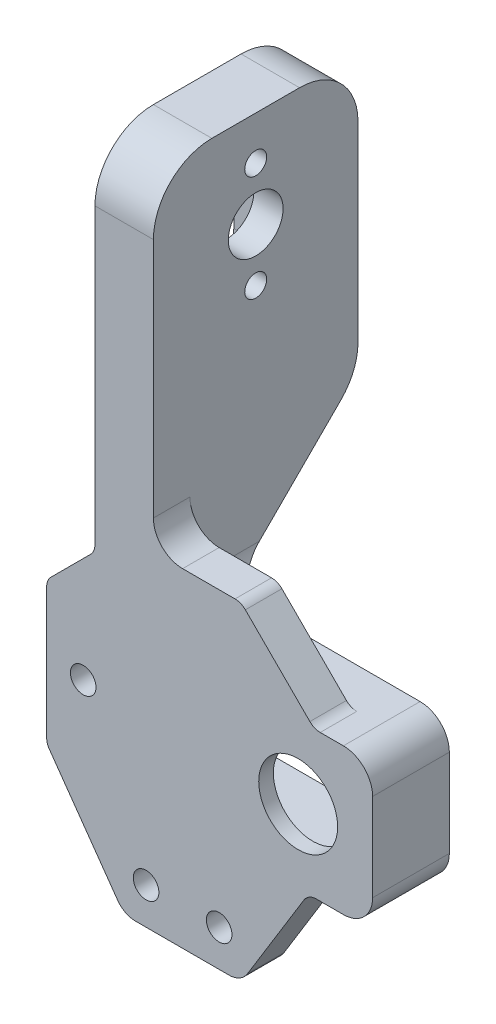
from build123d import *

# Parameters (mm, degrees)
IZIM1_R                     = 5.4
IZIM1_R_2                   = 1.75
Y_KSEKLIK_EKSTR_ZYON1_DEPTH = 10.5
IZIM3_W                     = 5.5
IZIM3_H                     = 14
KES_EKSTR_ZYON1_DEPTH       = 34.5
KES_EKSTR_ZYON2_DEPTH       = 34.5
KES_EKSTR_ZYON2_DEPTH_BACK  = 34.5
IZIM5_W                     = 6.606601718
IZIM5_H                     = 5.5
KES_EKSTR_ZYON4_DEPTH       = 50.5
KES_EKSTR_ZYON5_DEPTH       = 5.5
Y_KSEKLIK_EKSTR_ZYON2_DEPTH = 8
RADYUS2_R                   = 8
RADYUS7_R                   = 4
IZIM9_W                     = 23
IZIM9_H                     = 13
KES_EKSTR_ZYON6_DEPTH       = 8.5
IZIM10_R                    = 1
KES_EKSTR_ZYON7_DEPTH       = 6
KES_EKSTR_ZYON8_DEPTH       = 4
IZIM12_R                    = 1.3
IZIM12_R_2                  = 2.5
KES_EKSTR_ZYON9_DEPTH       = 8
IZIM13_R                    = 2.5
Y_KSEKLIK_EKSTR_ZYON4_DEPTH = 8
IZIM14_R                    = 3.75
IZIM14_R_2                  = 1.5
KES_EKSTR_ZYON10_DEPTH      = 8
IZIM15_W                    = 10
IZIM15_H                    = 20
IZIM15_R                    = 1.5
KES_EKSTR_ZYON11_DEPTH      = 4
RADYUS10_R                  = 3
RADYUS11_R                  = 3
RADYUS12_R                  = 3
RADYUS13_R                  = 3


with BuildPart() as part:
    # Çizim1 → Yükseklik-Ekstrüzyon1 (new body)
    with BuildSketch(Plane.XY):
        with BuildLine():
            ThreePointArc((-10.23959488, -42.821815771), (-10.512642946, -42.272926126), (-10.606601718, -41.667115232))
            Line((-10.606601718, -41.667115232), (-10.606601718, -23.737818565))
            ThreePointArc((-10.606601718, -23.737818565), (-10.454360783, -22.972451701), (-10.02081528, -22.323605003))
            Line((-10.02081528, -22.323605003), (-4.585786438, -16.888576161))
            ThreePointArc((-4.585786438, -16.888576161), (-4.152240935, -16.239729463), (-4, -15.474362598))
            Line((-4, -15.474362598), (-4, -12.302789723))
            Line((-4, -12.302789723), (-4, 32.697210277))
            Line((-4, 32.697210277), (4, 32.697210277))
            Line((4, 32.697210277), (4, -8.302789723))
            ThreePointArc((4, -8.302789723), (5.171572875, -11.131216848), (8, -12.302789723))
            Line((8, -12.302789723), (15.171572875, -12.302789723))
            ThreePointArc((15.171572875, -12.302789723), (15.93693974, -12.455030658), (16.585786438, -12.888576161))
            Line((16.585786438, -12.888576161), (25.414213562, -21.717003285))
            ThreePointArc((25.414213562, -21.717003285), (26.06306026, -22.150548788), (26.828427125, -22.302789723))
            Line((26.828427125, -22.302789723), (30, -22.302789723))
            ThreePointArc((30, -22.302789723), (32.828427125, -23.474362598), (34, -26.302789723))
            Line((34, -26.302789723), (34, -38.302789723))
            ThreePointArc((34, -38.302789723), (32.828427125, -41.131216848), (30, -42.302789723))
            Line((30, -42.302789723), (26.317150887, -42.302789723))
            ThreePointArc((26.317150887, -42.302789723), (25.340138032, -42.557669131), (24.612145635, -43.257343842))
            Line((24.612145635, -43.257343842), (16.877945687, -55.870958544))
            ThreePointArc((16.877945687, -55.870958544), (15.785957092, -56.920470611), (14.320437809, -57.302789723))
            Line((14.320437809, -57.302789723), (1.552914271, -57.302789723))
            ThreePointArc((1.552914271, -57.302789723), (0.17381174, -56.967011225), (-0.896575472, -56.03484053))
            Line((-0.896575472, -56.03484053), (-10.23959488, -42.821815771))
        make_face()
        with Locations((23.814213562, -32.302789723)):
            Circle(IZIM1_R, mode=Mode.SUBTRACT)
        with Locations((-5.606601718, -32.302789723)):
            Circle(IZIM1_R_2, mode=Mode.SUBTRACT)
        with Locations((13, -52.302789723)):
            Circle(IZIM1_R_2, mode=Mode.SUBTRACT)
        with Locations((3, -52.302789723)):
            Circle(IZIM1_R_2, mode=Mode.SUBTRACT)
    extrude(amount=Y_KSEKLIK_EKSTR_ZYON1_DEPTH)

    # Çizim3 → Kes-Ekstrüzyon1 (cut)
    with BuildSketch(Plane(origin=(4, 0, 0), x_dir=(0, 0, -1), z_dir=(1, 0, 0))):
        with Locations((-2.75, -15.302789723)):
            Rectangle(IZIM3_W, IZIM3_H)
    extrude(amount=KES_EKSTR_ZYON1_DEPTH, mode=Mode.SUBTRACT)

    # Çizim4 → Kes-Ekstrüzyon2 (cut, two sides)
    with BuildSketch(Plane(origin=(0, 0, 0), x_dir=(0, 0, -1), z_dir=(1, 0, 0))) as kes_ekstr_zyon2_sk:
        Polygon((-5.5, -42.821815771), (-5.5, -42.302789723), (0, -42.302789723), (0, -42.821815771), (0, -57.302789723), (-5.5, -57.302789723), align=None)
    extrude(amount=KES_EKSTR_ZYON2_DEPTH, mode=Mode.SUBTRACT)
    extrude(kes_ekstr_zyon2_sk.sketch, amount=-KES_EKSTR_ZYON2_DEPTH_BACK, mode=Mode.SUBTRACT)

    # Çizim5 → Kes-Ekstrüzyon4 (cut)
    with BuildSketch(Plane(origin=(0, 0, 0), x_dir=(1, 0, 0), z_dir=(0, 1, 0))):
        with Locations((-7.303300859, -2.75)):
            Rectangle(IZIM5_W, IZIM5_H)
    extrude(amount=-KES_EKSTR_ZYON4_DEPTH, mode=Mode.SUBTRACT)

    # Çizim7 → Kes-Ekstrüzyon5 (cut)
    with BuildSketch(Plane.XY):
        with BuildLine():
            Line((-4.606601718, -22.909391441), (-10.606601718, -22.909391441))
            Line((-10.606601718, -22.909391441), (-12.80795169, -22.909391441))
            Line((-12.80795169, -22.909391441), (-12.80795169, -45.448338302))
            Line((-12.80795169, -45.448338302), (4.393398282, -45.448338302))
            Line((4.393398282, -45.448338302), (4.393398282, -42.302789723))
            ThreePointArc((4.393398282, -42.302789723), (0.857864376, -40.838323629), (-0.606601718, -37.302789723))
            Line((-0.606601718, -37.302789723), (-0.606601718, -26.909391441))
            ThreePointArc((-0.606601718, -26.909391441), (-1.778174593, -24.080964316), (-4.606601718, -22.909391441))
        make_face()
    extrude(amount=KES_EKSTR_ZYON5_DEPTH, mode=Mode.SUBTRACT)

    # Çizim8 → Yükseklik-Ekstrüzyon2 (add)
    with BuildSketch(Plane(origin=(4, 0, 0), x_dir=(0, 0, -1), z_dir=(1, 0, 0))):
        with BuildLine():
            Line((-10.5, 32.697210277), (9.5, 32.697210277))
            ThreePointArc((9.5, 32.697210277), (15.156854249, 30.354064527), (17.5, 24.697210277))
            Line((17.5, 24.697210277), (17.5, -1.336305369))
            Line((17.5, -1.336305369), (17.5, -1.489081224))
            ThreePointArc((17.5, -1.489081224), (16.89103626, -4.550548683), (15.156854249, -7.145935473))
            Line((15.156854249, -7.145935473), (0, -22.302789723))
            Line((0, -22.302789723), (-10.5, -22.302789723))
            Line((-10.5, -22.302789723), (-10.5, 32.697210277))
        make_face()
    extrude(amount=-Y_KSEKLIK_EKSTR_ZYON2_DEPTH)

    # Radyus2
    radyus2_edges = [part.edges().sort_by_distance(p)[0] for p in [
        (0, 32.697210277, 10.5),
    ]]
    fillet(radyus2_edges, radius=RADYUS2_R)

    # Radyus7
    radyus7_edges = [part.edges().sort_by_distance(p)[0] for p in [
        (4, -22.302789723, 2.75),
    ]]
    fillet(radyus7_edges, radius=RADYUS7_R)

    # Çizim9 → Kes-Ekstrüzyon6 (cut)
    with BuildSketch(Plane.XY):
        with Locations((18.5, -32.302789723)):
            Rectangle(IZIM9_W, IZIM9_H)
    extrude(amount=KES_EKSTR_ZYON6_DEPTH, mode=Mode.SUBTRACT)

    # Çizim10 → Kes-Ekstrüzyon7 (cut)
    with BuildSketch(Plane.XY):
        with Locations((32, -32.302789723)):
            Circle(IZIM10_R)
        with Locations((5, -32.302789723)):
            Circle(IZIM10_R)
    extrude(amount=KES_EKSTR_ZYON7_DEPTH, mode=Mode.SUBTRACT)

    # Çizim11 → Kes-Ekstrüzyon8 (cut)
    with BuildSketch(Plane.ZY.offset(4)):
        with BuildLine():
            Line((-6.5, 14.197210277), (-6.5, 23.197210277))
            ThreePointArc((-6.5, 23.197210277), (-3.5, 26.197210277), (-0.5, 23.197210277))
            Line((-0.5, 23.197210277), (-0.5, 14.197210277))
            ThreePointArc((-0.5, 14.197210277), (-3.5, 11.197210277), (-6.5, 14.197210277))
        make_face()
    extrude(amount=-KES_EKSTR_ZYON8_DEPTH, mode=Mode.SUBTRACT)

    # Çizim12 → Kes-Ekstrüzyon9 (cut)
    with BuildSketch(Plane.ZY.offset(4)):
        with Locations((-3.5, 23.197210277)):
            Circle(IZIM12_R)
        with Locations((-3.5, 14.197210277)):
            Circle(IZIM12_R)
        with Locations((-3.5, 18.697210277)):
            Circle(IZIM12_R_2)
    extrude(amount=-KES_EKSTR_ZYON9_DEPTH, mode=Mode.SUBTRACT)

    # Çizim13 → Yükseklik-Ekstrüzyon4 (add)
    with BuildSketch(Plane(origin=(4, 0, 0), x_dir=(0, 0, -1), z_dir=(1, 0, 0))):
        Polygon((-4.189470597, 27.846393302), (11.202467705, 28.228364897), (11.683763176, 8.834068822), (-4.189470597, 8.440153234), align=None)
        with Locations((3.5, 18.697210277)):
            Circle(IZIM13_R, mode=Mode.SUBTRACT)
    extrude(amount=-Y_KSEKLIK_EKSTR_ZYON4_DEPTH)

    # Çizim14 → Kes-Ekstrüzyon10 (cut)
    with BuildSketch(Plane(origin=(4, 0, 0), x_dir=(0, 0, -1), z_dir=(1, 0, 0))):
        with Locations((3.5, 19.50634608)):
            Circle(IZIM14_R)
        with Locations((3.5, 12.25634608)):
            Circle(IZIM14_R_2)
        with Locations((3.5, 26.75634608)):
            Circle(IZIM14_R_2)
    extrude(amount=-KES_EKSTR_ZYON10_DEPTH, mode=Mode.SUBTRACT)

    # Çizim15 → Kes-Ekstrüzyon11 (cut)
    with BuildSketch(Plane.ZY.offset(4)):
        with Locations((-3.5, 19.50634608)):
            Rectangle(IZIM15_W, IZIM15_H)
        with Locations((-3.5, 26.75634608)):
            Circle(IZIM15_R, mode=Mode.SUBTRACT)
    extrude(amount=-KES_EKSTR_ZYON11_DEPTH, mode=Mode.SUBTRACT)

    # Radyus10
    radyus10_edges = [part.edges().sort_by_distance(p)[0] for p in [
        (-2, 29.50634608, 1.5),
    ]]
    fillet(radyus10_edges, radius=RADYUS10_R)

    # Radyus11
    radyus11_edges = [part.edges().sort_by_distance(p)[0] for p in [
        (-2, 9.50634608, -8.5),
    ]]
    fillet(radyus11_edges, radius=RADYUS11_R)

    # Radyus12
    radyus12_edges = [part.edges().sort_by_distance(p)[0] for p in [
        (-2, 29.50634608, -8.5),
    ]]
    fillet(radyus12_edges, radius=RADYUS12_R)

    # Radyus13
    radyus13_edges = [part.edges().sort_by_distance(p)[0] for p in [
        (-2, 9.50634608, 1.5),
    ]]
    fillet(radyus13_edges, radius=RADYUS13_R)


solid = part.part
